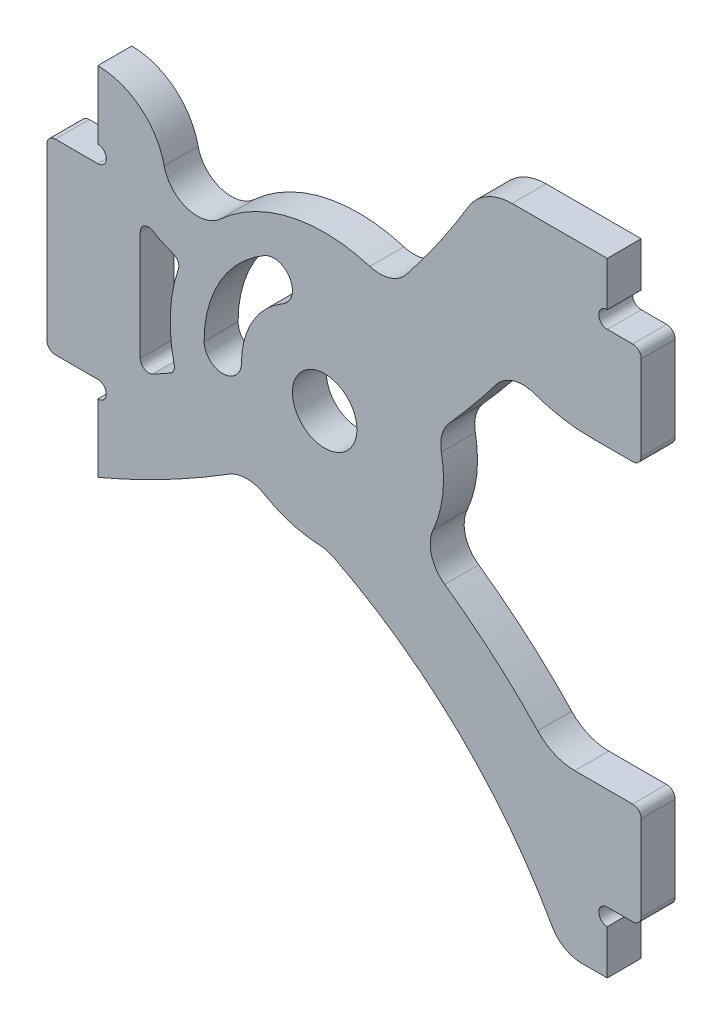
from build123d import *

# Parameters (mm, degrees)
BOSS_EXTRUDE1_DEPTH        = 2
M3_5_CLEARANCE_HOLE1_D     = 3.8
M3_5_CLEARANCE_HOLE1_DEPTH = 2


with BuildPart() as part:
    # Sketch1 → Boss-Extrude1 (new body)
    with BuildSketch(Plane.XY):
        with BuildLine():
            Line((18.63883017, -16.482761143), (18.63883017, -11.482761143))
            ThreePointArc((18.63883017, -11.482761143), (18.492383561, -11.129207753), (18.13883017, -10.982761143))
            Line((18.13883017, -10.982761143), (14.726824149, -10.982761143))
            ThreePointArc((14.726824149, -10.982761143), (13.539431255, -10.737774413), (12.545968697, -10.042826553))
            ThreePointArc((12.545968697, -10.042826553), (9.927684451, -7.539157578), (7.068753945, -5.314233513))
            ThreePointArc((7.068753945, -5.314233513), (6.287636427, -4.208593434), (6.389660154, -2.858713543))
            ThreePointArc((6.389660154, -2.858713543), (6.954343162, -0.798192452), (6.871191626, 1.336684568))
            ThreePointArc((6.871191626, 1.336684568), (6.905834234, 2.248382718), (7.341806065, 3.049832772))
            ThreePointArc((7.341806065, 3.049832772), (8.751272055, 4.692211544), (10.096999644, 6.387209969))
            ThreePointArc((10.096999644, 6.387209969), (11.122804542, 7.092577212), (12.367138803, 7.054486744))
            ThreePointArc((12.367138803, 7.054486744), (13.978037739, 6.625408008), (15.63883017, 6.480935011))
            Line((15.63883017, 6.480935011), (18.13883017, 6.480935011))
            ThreePointArc((18.13883017, 6.480935011), (18.492383561, 6.62738162), (18.63883017, 6.980935011))
            Line((18.63883017, 6.980935011), (18.63883017, 11.980935011))
            ThreePointArc((18.63883017, 11.980935011), (18.492383561, 12.334488401), (18.13883017, 12.480935011))
            Line((18.13883017, 12.480935011), (16.63883017, 12.480935011))
            ThreePointArc((16.63883017, 12.480935011), (16.13883017, 12.980935011), (16.63883017, 13.480935011))
            Line((16.63883017, 13.480935011), (16.63883017, 16.099008984))
            Line((16.63883017, 16.099008984), (11.035994897, 16.099008984))
            ThreePointArc((11.035994897, 16.099008984), (9.559562701, 15.710550285), (8.465485791, 14.645774297))
            ThreePointArc((8.465485791, 14.645774297), (6.726327278, 11.952270464), (4.820305649, 9.37414774))
            ThreePointArc((4.820305649, 9.37414774), (3.846646619, 8.704308056), (2.664831641, 8.701073056))
            ThreePointArc((2.664831641, 8.701073056), (-2.003730385, 8.876658411), (-6.144167501, 6.712615415))
            ThreePointArc((-6.144167501, 6.712615415), (-8.103077659, 6.282745016), (-9.450079267, 7.768579541))
            ThreePointArc((-9.450079267, 7.768579541), (-10.84668059, 10.040750561), (-13.36116983, 10.92990761))
            Line((-13.36116983, 10.92990761), (-13.36116983, 6.92990761))
            ThreePointArc((-13.36116983, 6.92990761), (-12.86116983, 6.42990761), (-13.36116983, 5.92990761))
            Line((-13.36116983, 5.92990761), (-15.86116983, 5.92990761))
            ThreePointArc((-15.86116983, 5.92990761), (-16.21472322, 5.783461001), (-16.36116983, 5.42990761))
            Line((-16.36116983, 5.42990761), (-16.36116983, -4.57009239))
            ThreePointArc((-16.36116983, -4.57009239), (-16.21472322, -4.92364578), (-15.86116983, -5.07009239))
            Line((-15.86116983, -5.07009239), (-13.36116983, -5.07009239))
            ThreePointArc((-13.36116983, -5.07009239), (-12.86116983, -5.57009239), (-13.36116983, -6.07009239))
            Line((-13.36116983, -6.07009239), (-13.36116983, -10.07009239))
            ThreePointArc((-13.36116983, -10.07009239), (-9.424252929, -8.211858727), (-5.645907876, -6.049347295))
            ThreePointArc((-5.645907876, -6.049347295), (-4.609540233, -5.744803026), (-3.565955999, -6.023616672))
            ThreePointArc((-3.565955999, -6.023616672), (-1.987644312, -6.711875303), (-0.289069284, -6.994028807))
            ThreePointArc((-0.289069284, -6.994028807), (0.134843139, -7.057521972), (0.535490188, -7.209886886))
            ThreePointArc((0.535490188, -7.209886886), (7.881477412, -12.437026609), (13.387941825, -19.576029874))
            ThreePointArc((13.387941825, -19.576029874), (14.121752395, -20.325710404), (15.134079043, -20.600835116))
            Line((15.134079043, -20.600835116), (16.63883017, -20.600835116))
            Line((16.63883017, -20.600835116), (16.63883017, -17.982761143))
            ThreePointArc((16.63883017, -17.982761143), (16.13883017, -17.482761143), (16.63883017, -16.982761143))
            Line((16.63883017, -16.982761143), (18.13883017, -16.982761143))
            ThreePointArc((18.13883017, -16.982761143), (18.492383561, -16.836314534), (18.63883017, -16.482761143))
        make_face()
        with BuildLine():
            Line((-10.86116983, -2.746889398), (-10.86116983, 3.698246713))
            ThreePointArc((-10.86116983, 3.698246713), (-10.599535477, 4.13777125), (-10.088442557, 4.117316916))
            ThreePointArc((-10.088442557, 4.117316916), (-9.528608488, 3.802221602), (-8.932994407, 3.561507855))
            ThreePointArc((-8.932994407, 3.561507855), (-8.642555945, 3.309647034), (-8.616730153, 2.926082957))
            ThreePointArc((-8.616730153, 2.926082957), (-9.089130193, 0.444648546), (-8.861194309, -2.071046938))
            ThreePointArc((-8.861194309, -2.071046938), (-8.88986137, -2.384945686), (-9.100629521, -2.619319341))
            ThreePointArc((-9.100629521, -2.619319341), (-9.610484862, -2.905923033), (-10.123517324, -3.186799942))
            ThreePointArc((-10.123517324, -3.186799942), (-10.617269173, -3.176322893), (-10.86116983, -2.746889398))
        make_face(mode=Mode.SUBTRACT)
        with BuildLine():
            ThreePointArc((-3.55, 6.148780367), (-6.148780367, 3.55), (-7.1, 0))
            ThreePointArc((-7.1, 0), (-6, -1.1), (-4.9, 0))
            ThreePointArc((-4.9, 0), (-4.243524479, 2.45), (-2.45, 4.243524479))
            ThreePointArc((-2.45, 4.243524479), (-2.047372056, 5.746152423), (-3.55, 6.148780367))
        make_face(mode=Mode.SUBTRACT)
    extrude(amount=BOSS_EXTRUDE1_DEPTH)

    # M3.5 Clearance Hole1
    with Locations(Plane(origin=(0, 0, 0), x_dir=(-1, 0, 0), z_dir=(0, 0, -1))):
        with Locations((0, 0)):
            Hole(M3_5_CLEARANCE_HOLE1_D / 2, depth=M3_5_CLEARANCE_HOLE1_DEPTH)


solid = part.part
